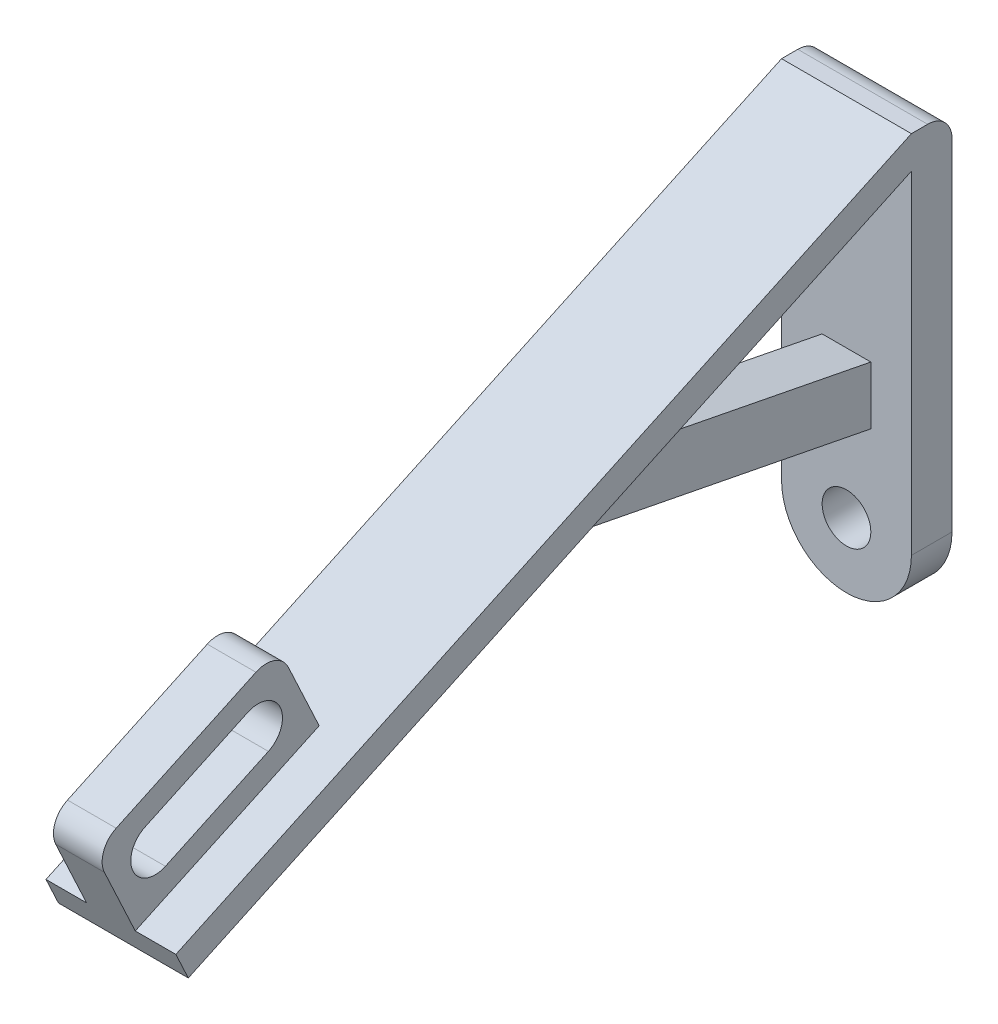
from build123d import *

# Parameters (mm, degrees)
CROQUIS1_R                   = 3
SALIENTE_EXTRUIR1_DEPTH      = 5
SALIENTE_EXTRUIR2_DEPTH      = 16
SALIENTE_EXTRUIR3_DEPTH      = 3
SALIENTE_EXTRUIR3_DEPTH_BACK = 3
SALIENTE_EXTRUIR4_DEPTH      = 3
SALIENTE_EXTRUIR4_DEPTH_BACK = 3
REDONDEO1_R                  = 3


with BuildPart() as part:
    # Croquis1 → Saliente-Extruir1 (new body)
    with BuildSketch(Plane.XY):
        with BuildLine():
            Line((-8, 0), (-8, 45))
            Line((-8, 45), (8, 45))
            Line((8, 45), (8, 0))
            ThreePointArc((8, 0), (0, -8), (-8, 0))
        make_face()
        Circle(CROQUIS1_R, mode=Mode.SUBTRACT)
    extrude(amount=SALIENTE_EXTRUIR1_DEPTH)

    # Croquis2 → Saliente-Extruir2 (add)
    with BuildSketch(Plane.ZY.offset(8)):
        Polygon((5, 45), (95.630778704, 2.738173826), (94.098689817, -0.547401393), (5, 41), align=None)
    extrude(amount=-SALIENTE_EXTRUIR2_DEPTH)

    # Croquis3 → Saliente-Extruir3 (add, two sides)
    with BuildSketch(Plane(origin=(0, 0, 0), x_dir=(0, 0, -1), z_dir=(1, 0, 0))) as saliente_extruir3_sk:
        Polygon((-5, 11), (-50.315389352, 19.869086913), (-39.541185822, 24.893180529), (-5, 18.132810961), align=None)
    extrude(amount=SALIENTE_EXTRUIR3_DEPTH)
    extrude(saliente_extruir3_sk.sketch, amount=-SALIENTE_EXTRUIR3_DEPTH_BACK)

    # Croquis4 → Saliente-Extruir4 (add, two sides)
    with BuildSketch(Plane(origin=(0, 0, 0), x_dir=(0, 0, -1), z_dir=(1, 0, 0))) as saliente_extruir4_sk:
        Polygon((-95.630778704, 2.738173826), (-100.702197845, 13.61386727), (-78.044503169, 24.179323814), (-72.973084028, 13.303630369), align=None)
        with BuildLine():
            Line((-79.225631642, 13.698153291), (-91.91394066, 7.781497627))
            ThreePointArc((-91.91394066, 7.781497627), (-95.900718807, 9.232566203), (-94.449650231, 13.219344349))
            Line((-94.449650231, 13.219344349), (-81.761341212, 19.136000013))
            ThreePointArc((-81.761341212, 19.136000013), (-77.774563066, 17.684931437), (-79.225631642, 13.698153291))
        make_face(mode=Mode.SUBTRACT)
    extrude(amount=SALIENTE_EXTRUIR4_DEPTH)
    extrude(saliente_extruir4_sk.sketch, amount=-SALIENTE_EXTRUIR4_DEPTH_BACK)

    # Redondeo1
    redondeo1_edges = [part.edges().sort_by_distance(p)[0] for p in [
        (0, 13.61386727, 100.702197845),
        (0, 24.179323814, 78.044503169),
        (0, 45, 0),
    ]]
    fillet(redondeo1_edges, radius=REDONDEO1_R)


solid = part.part
